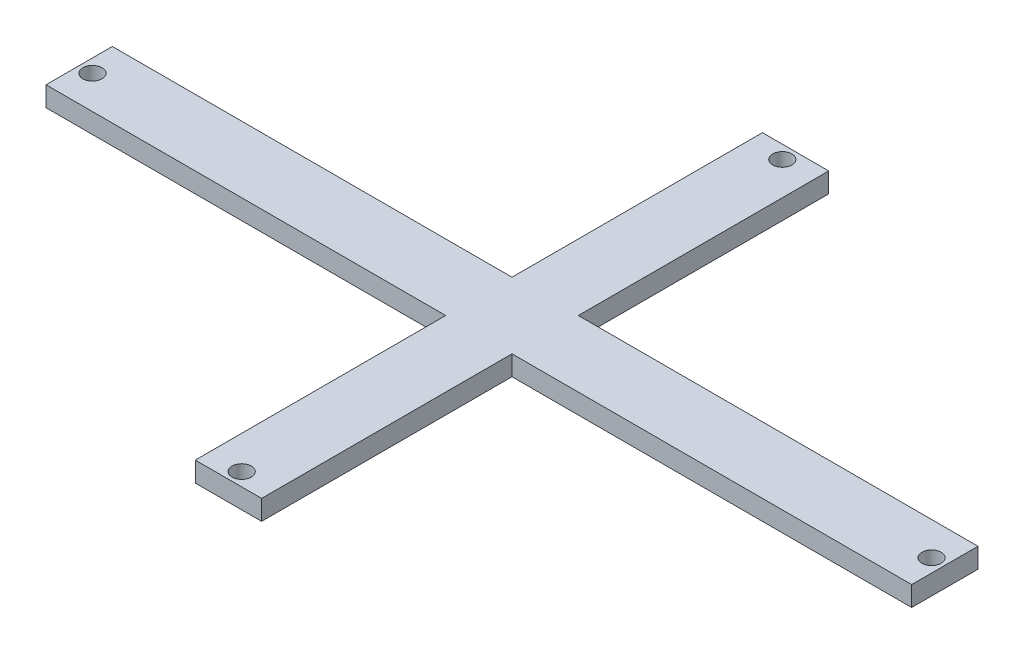
from build123d import *

# Parameters (mm, degrees)
SKETCH1_W                  = 130.5
SKETCH1_H                  = 10
SKETCH1_W_2                = 10
SKETCH1_H_2                = 85.5
BOSS_EXTRUDE1_DEPTH        = 3
M2_5_CLEARANCE_HOLE1_D     = 2.9
M2_5_CLEARANCE_HOLE1_DEPTH = 3
M2_5_CLEARANCE_HOLE1_TIP   = 0.871247898
M2_5_CLEARANCE_HOLE2_D     = 2.9
M2_5_CLEARANCE_HOLE2_DEPTH = 3
M2_5_CLEARANCE_HOLE2_TIP   = 0.871247898
M2_5_CLEARANCE_HOLE3_D     = 2.9
M2_5_CLEARANCE_HOLE3_DEPTH = 3
M2_5_CLEARANCE_HOLE3_TIP   = 0.871247898
M2_5_CLEARANCE_HOLE4_D     = 2.9
M2_5_CLEARANCE_HOLE4_DEPTH = 3
M2_5_CLEARANCE_HOLE4_TIP   = 0.871247898


with BuildPart() as part:
    # Sketch1 → Boss-Extrude1 (new body)
    with BuildSketch(Plane(origin=(0, 0, 0), x_dir=(1, 0, 0), z_dir=(0, 1, 0))):
        with Locations((40.207417437, 2.647058824)):
            Rectangle(SKETCH1_W, SKETCH1_H)
        with Locations((40.207417437, 2.647058824)):
            Rectangle(SKETCH1_W_2, SKETCH1_H_2)
    extrude(amount=BOSS_EXTRUDE1_DEPTH)

    # M2.5 Clearance Hole1
    with Locations(Plane(origin=(0, 3, 0), x_dir=(1, 0, 0), z_dir=(0, 1, 0))):
        with Locations((-23.042582563, 2.647058824)):
            Hole(M2_5_CLEARANCE_HOLE1_D / 2, depth=M2_5_CLEARANCE_HOLE1_DEPTH)
            with Locations((0, 0, -(M2_5_CLEARANCE_HOLE1_DEPTH + M2_5_CLEARANCE_HOLE1_TIP / 2))):  # 118° drill point
                Cone(0, M2_5_CLEARANCE_HOLE1_D / 2, M2_5_CLEARANCE_HOLE1_TIP, mode=Mode.SUBTRACT)

    # M2.5 Clearance Hole2
    with Locations(Plane(origin=(0, 3, 0), x_dir=(1, 0, 0), z_dir=(0, 1, 0))):
        with Locations((40.207417437, 43.397058824)):
            Hole(M2_5_CLEARANCE_HOLE2_D / 2, depth=M2_5_CLEARANCE_HOLE2_DEPTH)
            with Locations((0, 0, -(M2_5_CLEARANCE_HOLE2_DEPTH + M2_5_CLEARANCE_HOLE2_TIP / 2))):  # 118° drill point
                Cone(0, M2_5_CLEARANCE_HOLE2_D / 2, M2_5_CLEARANCE_HOLE2_TIP, mode=Mode.SUBTRACT)

    # M2.5 Clearance Hole3
    with Locations(Plane(origin=(0, 3, 0), x_dir=(1, 0, 0), z_dir=(0, 1, 0))):
        with Locations((103.457417437, 2.647058824)):
            Hole(M2_5_CLEARANCE_HOLE3_D / 2, depth=M2_5_CLEARANCE_HOLE3_DEPTH)
            with Locations((0, 0, -(M2_5_CLEARANCE_HOLE3_DEPTH + M2_5_CLEARANCE_HOLE3_TIP / 2))):  # 118° drill point
                Cone(0, M2_5_CLEARANCE_HOLE3_D / 2, M2_5_CLEARANCE_HOLE3_TIP, mode=Mode.SUBTRACT)

    # M2.5 Clearance Hole4
    with Locations(Plane(origin=(0, 3, 0), x_dir=(1, 0, 0), z_dir=(0, 1, 0))):
        with Locations((40.207417437, -38.102941176)):
            Hole(M2_5_CLEARANCE_HOLE4_D / 2, depth=M2_5_CLEARANCE_HOLE4_DEPTH)
            with Locations((0, 0, -(M2_5_CLEARANCE_HOLE4_DEPTH + M2_5_CLEARANCE_HOLE4_TIP / 2))):  # 118° drill point
                Cone(0, M2_5_CLEARANCE_HOLE4_D / 2, M2_5_CLEARANCE_HOLE4_TIP, mode=Mode.SUBTRACT)


solid = part.part
